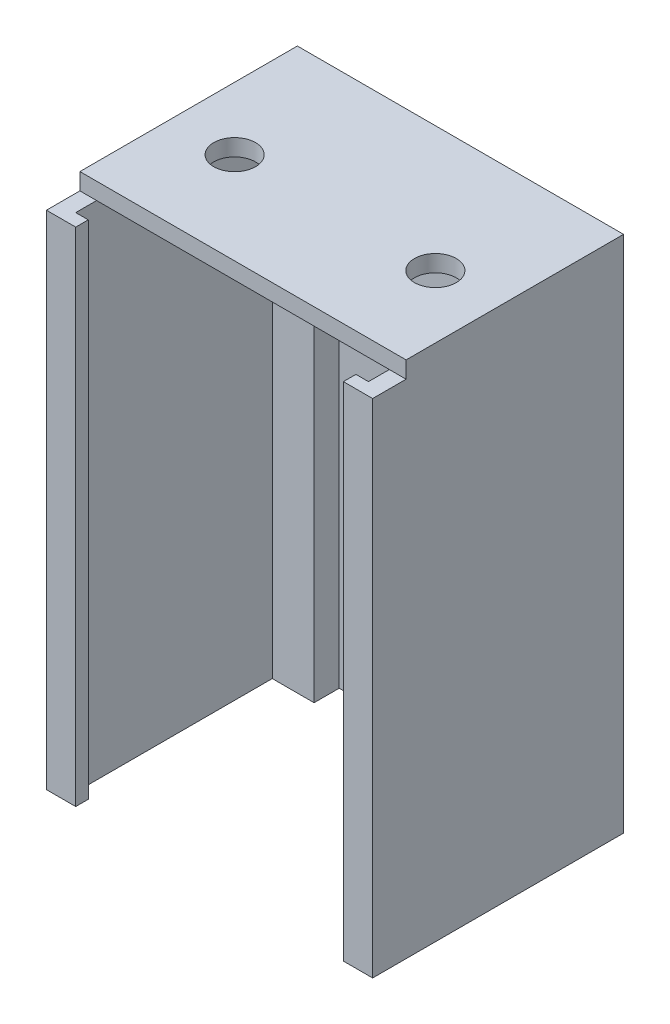
from build123d import *

# Parameters (mm, degrees)
BOSS_EXTRU_2_DEPTH      = 120
ESQUISSE2_R             = 2.25
ENL_V_MAT_EXTRU_1_DEPTH = 5
ESQUISSE4_W             = 78
ESQUISSE4_H             = 52
BOSS_EXTRU_3_DEPTH      = 4
ESQUISSE6_R             = 5
ENL_V_MAT_EXTRU_3_DEPTH = 10


with BuildPart() as part:
    # Esquisse1 → Boss.-Extru.2 (new body)
    with BuildSketch(Plane(origin=(0, 0, 0), x_dir=(1, 0, 0), z_dir=(0, 1, 0))):
        Polygon((71, -60), (78, -60), (78, 0), (0, 0), (0, -60), (7, -60), (7, -57), (4, -57), (4, -10), (14, -10), (14, -4), (64, -4), (64, -10), (74, -10), (74, -57), (71, -57), align=None)
    extrude(amount=BOSS_EXTRU_2_DEPTH)

    # Esquisse2 → Enlèv. mat.-Extru.1 (cut)
    with BuildSketch(Plane.XZ):
        with Locations((69, 5)):
            Circle(ESQUISSE2_R)
        with Locations((9, 5)):
            Circle(ESQUISSE2_R)
    extrude(amount=-ENL_V_MAT_EXTRU_1_DEPTH, mode=Mode.SUBTRACT)

    # Esquisse4 → Boss.-Extru.3 (add)
    with BuildSketch(Plane(origin=(0, 120, 0), x_dir=(1, 0, 0), z_dir=(0, 1, 0))):
        with Locations((39, -26)):
            Rectangle(ESQUISSE4_W, ESQUISSE4_H)
    extrude(amount=BOSS_EXTRU_3_DEPTH)

    # Esquisse6 → Enlèv. mat.-Extru.3 (cut)
    with BuildSketch(Plane(origin=(0, 124, 0), x_dir=(1, 0, 0), z_dir=(0, 1, 0))):
        with Locations((15, -30)):
            Circle(ESQUISSE6_R)
        with Locations((63, -30)):
            Circle(ESQUISSE6_R)
    extrude(amount=-ENL_V_MAT_EXTRU_3_DEPTH, mode=Mode.SUBTRACT)


solid = part.part
